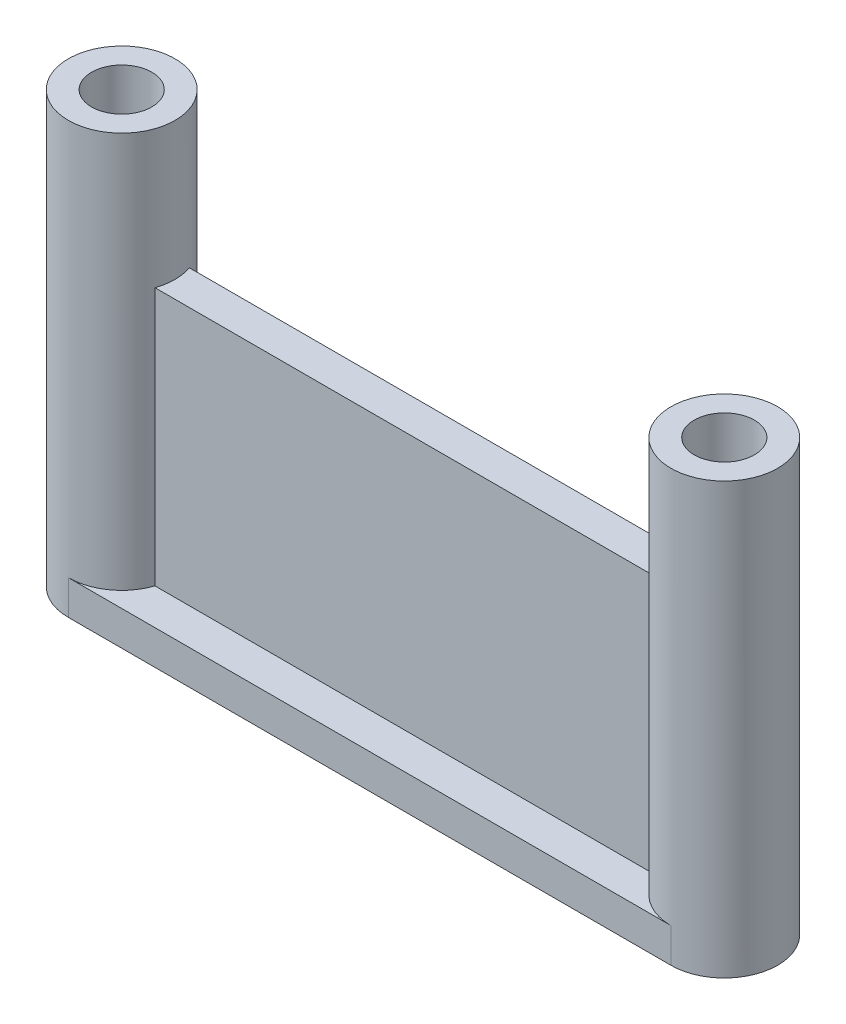
from build123d import *

# Parameters (mm, degrees)
SKETCH_1_R        = 3.1
SKETCH_1_R_2      = 1.75
EXTRUDE_1_DEPTH   = 25
EXTRUDE_1_2_DEPTH = 25
SKETCH_2_R        = 1.75
EXTRUDE_2_DEPTH   = 2
SKETCH_3_W        = 30.176052102
SKETCH_3_H        = 2
EXTRUDE_3_DEPTH   = 15


with BuildPart() as part:
    # Эскиз1 → Бобышка-Вытянуть1 (new body)
    with BuildSketch(Plane(origin=(0, 0, 0), x_dir=(1, 0, 0), z_dir=(0, 1, 0))):
        with Locations((-17.5, 0)):
            Circle(SKETCH_1_R)
        with Locations((-17.5, 0)):
            Circle(SKETCH_1_R_2, mode=Mode.SUBTRACT)
    extrude(amount=EXTRUDE_1_DEPTH)



with BuildPart() as body_2:
    # Эскиз1 → Extrude 1 2 (new body)
    with BuildSketch(Plane(origin=(0, 0, 0), x_dir=(1, 0, 0), z_dir=(0, 1, 0))):
        with Locations((17.5, 0)):
            Circle(SKETCH_1_R)
        with Locations((17.5, 0)):
            Circle(SKETCH_1_R_2, mode=Mode.SUBTRACT)
    extrude(amount=EXTRUDE_1_2_DEPTH)


with BuildPart() as part_1:
    add(part.part)

    add(body_2.part)  # Бобышка-Вытянуть2 merges body 2
    # Эскиз2 → Бобышка-Вытянуть2 (add)
    with BuildSketch(Plane.XZ):
        with BuildLine():
            Line((-17.5, 3.1), (17.5, 3.1))
            ThreePointArc((17.5, 3.1), (20.6, 0), (17.5, -3.1))
            Line((17.5, -3.1), (-17.5, -3.1))
            ThreePointArc((-17.5, -3.1), (-20.6, 0), (-17.5, 3.1))
        make_face()
        with Locations((-17.5, 0)):
            Circle(SKETCH_2_R, mode=Mode.SUBTRACT)
        with Locations((17.5, 0)):
            Circle(SKETCH_2_R, mode=Mode.SUBTRACT)
    extrude(amount=-EXTRUDE_2_DEPTH)

    # Эскиз3 → Бобышка-Вытянуть3 (add)
    with BuildSketch(Plane(origin=(0, 2, 0), x_dir=(1, 0, 0), z_dir=(0, 1, 0))):
        Rectangle(SKETCH_3_W, SKETCH_3_H)
    extrude(amount=EXTRUDE_3_DEPTH)


solid = part_1.part
